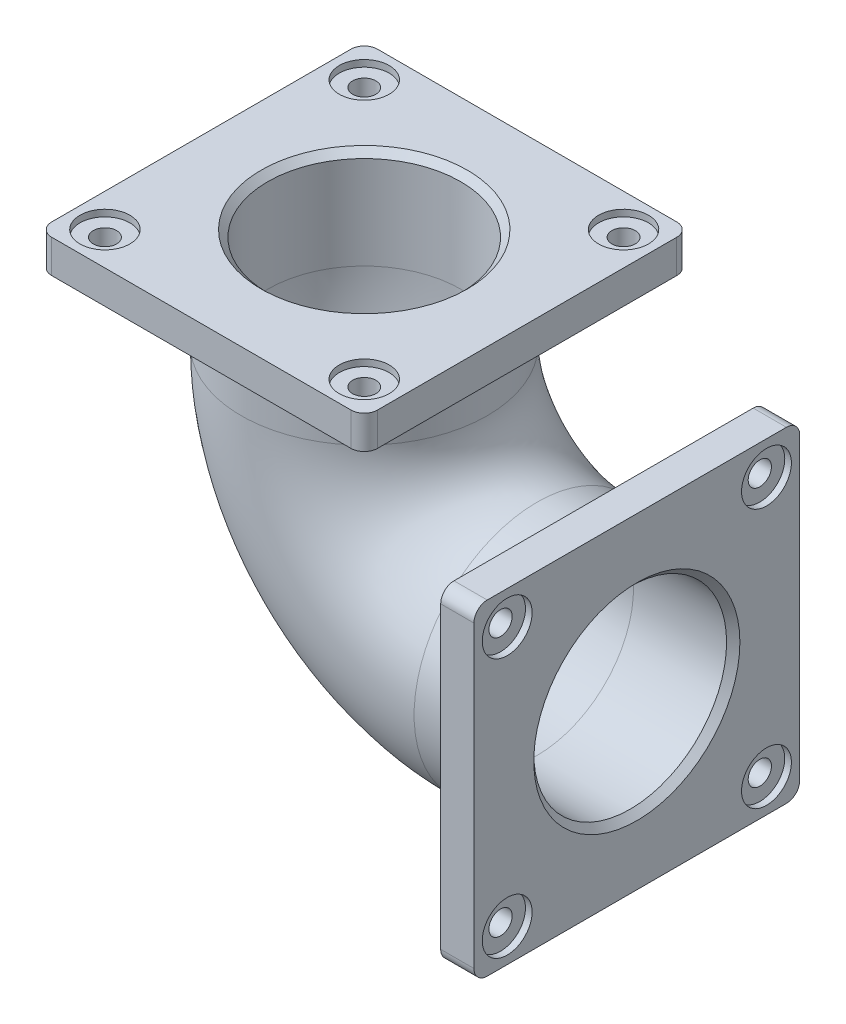
from build123d import *

# Parameters (mm, degrees)
SKETCH14_R          = 185
SKETCH14_R_2        = 145
SKETCH16_W          = 490
SKETCH16_H          = 490
SKETCH16_R          = 185
BOSS_EXTRUDE1_DEPTH = 50
FILLET2_R           = 20
SKETCH19_R          = 185
BOSS_EXTRUDE2_DEPTH = 50
SKETCH20_R          = 37.5
CUT_EXTRUDE1_DEPTH  = 10
SKETCH26_R          = 17.5
CUT_EXTRUDE3_DEPTH  = 40
CIRPATTERN1_COUNT   = 4
SKETCH28_R          = 37.5
CUT_EXTRUDE4_DEPTH  = 10
SKETCH30_R          = 17.5
CUT_EXTRUDE5_DEPTH  = 40
CIRPATTERN3_COUNT   = 4
CHAMFER1_SIZE       = 10
CHAMFER2_SIZE       = 10


with BuildPart() as part:
    # Sweep-Thin1: sweep along a path in Sketch13
    with BuildLine(Plane.XY) as sweep_thin1_path:
        Line((0, 0), (-150, 0))
        ThreePointArc((-150, 0), (-333.847763109, 76.152236891), (-410, 260))
        Line((-410, 260), (-410, 410))
    # Sketch14 → Sweep-Thin1 (sweep)
    with BuildSketch(Plane(origin=(0, 0, 0), x_dir=(0, 0, -1), z_dir=(1, 0, 0))):
        Circle(SKETCH14_R)
        Circle(SKETCH14_R_2, mode=Mode.SUBTRACT)
    sweep(path=sweep_thin1_path.line)

    # Sketch16 → Boss-Extrude1 (add)
    with BuildSketch(Plane(origin=(0, 0, 0), x_dir=(0, 0, -1), z_dir=(1, 0, 0))):
        Rectangle(SKETCH16_W, SKETCH16_H)
        Circle(SKETCH16_R, mode=Mode.SUBTRACT)
    extrude(amount=-BOSS_EXTRUDE1_DEPTH)

    # Fillet2
    fillet2_edges = [part.edges().sort_by_distance(p)[0] for p in [
        (-25, 245, -245),
        (-25, -245, -245),
        (-25, -245, 245),
        (-25, 245, 245),
    ]]
    fillet(fillet2_edges, radius=FILLET2_R)

    # Sketch19 → Boss-Extrude2 (add)
    with BuildSketch(Plane(origin=(0, 410, 0), x_dir=(1, 0, 0), z_dir=(0, 1, 0))):
        with BuildLine():
            Line((-635, -245), (-185, -245))
            ThreePointArc((-185, -245), (-170.857864376, -239.142135624), (-165, -225))
            Line((-165, -225), (-165, 225))
            ThreePointArc((-165, 225), (-170.857864376, 239.142135624), (-185, 245))
            Line((-185, 245), (-635, 245))
            ThreePointArc((-635, 245), (-649.142135624, 239.142135624), (-655, 225))
            Line((-655, 225), (-655, -225))
            ThreePointArc((-655, -225), (-649.142135624, -239.142135624), (-635, -245))
        make_face()
        with Locations((-410, 0)):
            Circle(SKETCH19_R, mode=Mode.SUBTRACT)
    extrude(amount=-BOSS_EXTRUDE2_DEPTH)

    # Sketch20 → Cut-Extrude1 (cut)
    with BuildSketch(Plane(origin=(0, 410, 0), x_dir=(1, 0, 0), z_dir=(0, 1, 0))):
        with Locations((-605, 195)):
            Circle(SKETCH20_R)
    cut_extrude1 = extrude(amount=-CUT_EXTRUDE1_DEPTH, mode=Mode.SUBTRACT)

    # Sketch26 → Cut-Extrude3 (cut)
    with BuildSketch(Plane(origin=(0, 400, 0), x_dir=(1, 0, 0), z_dir=(0, 1, 0))):
        with Locations((-605, 195)):
            Circle(SKETCH26_R)
    cut_extrude3 = extrude(amount=-CUT_EXTRUDE3_DEPTH, mode=Mode.SUBTRACT)

    # CirPattern1: Cut-Extrude1, Cut-Extrude3 ×4 about axis
    cirpattern1_axis = Axis((-410, 0, 0), (0, 1, 0))
    for i in range(1, CIRPATTERN1_COUNT):
        add(cut_extrude1.rotate(cirpattern1_axis, i * 360 / CIRPATTERN1_COUNT), mode=Mode.SUBTRACT)
        add(cut_extrude3.rotate(cirpattern1_axis, i * 360 / CIRPATTERN1_COUNT), mode=Mode.SUBTRACT)

    # Sketch28 → Cut-Extrude4 (cut)
    with BuildSketch(Plane(origin=(0, 0, 0), x_dir=(0, 0, -1), z_dir=(1, 0, 0))):
        with Locations((-195, 195)):
            Circle(SKETCH28_R)
    cut_extrude4 = extrude(amount=-CUT_EXTRUDE4_DEPTH, mode=Mode.SUBTRACT)

    # Sketch30 → Cut-Extrude5 (cut)
    with BuildSketch(Plane(origin=(-10, 0, 0), x_dir=(0, 0, -1), z_dir=(1, 0, 0))):
        with Locations((-195, 195)):
            Circle(SKETCH30_R)
    cut_extrude5 = extrude(amount=-CUT_EXTRUDE5_DEPTH, mode=Mode.SUBTRACT)

    # CirPattern3: Cut-Extrude4, Cut-Extrude5 ×4 about axis
    cirpattern3_axis = Axis((0, 0, 0), (1, 0, 0))
    for i in range(1, CIRPATTERN3_COUNT):
        add(cut_extrude4.rotate(cirpattern3_axis, i * 360 / CIRPATTERN3_COUNT), mode=Mode.SUBTRACT)
        add(cut_extrude5.rotate(cirpattern3_axis, i * 360 / CIRPATTERN3_COUNT), mode=Mode.SUBTRACT)

    # Chamfer1
    chamfer1_edges = [part.edges().sort_by_distance(p)[0] for p in [
        (0, 0, 145),
    ]]
    chamfer(chamfer1_edges, length=CHAMFER1_SIZE)

    # Chamfer2
    chamfer2_edges = [part.edges().sort_by_distance(p)[0] for p in [
        (-410, 410, 145),
    ]]
    chamfer(chamfer2_edges, length=CHAMFER2_SIZE)


solid = part.part
